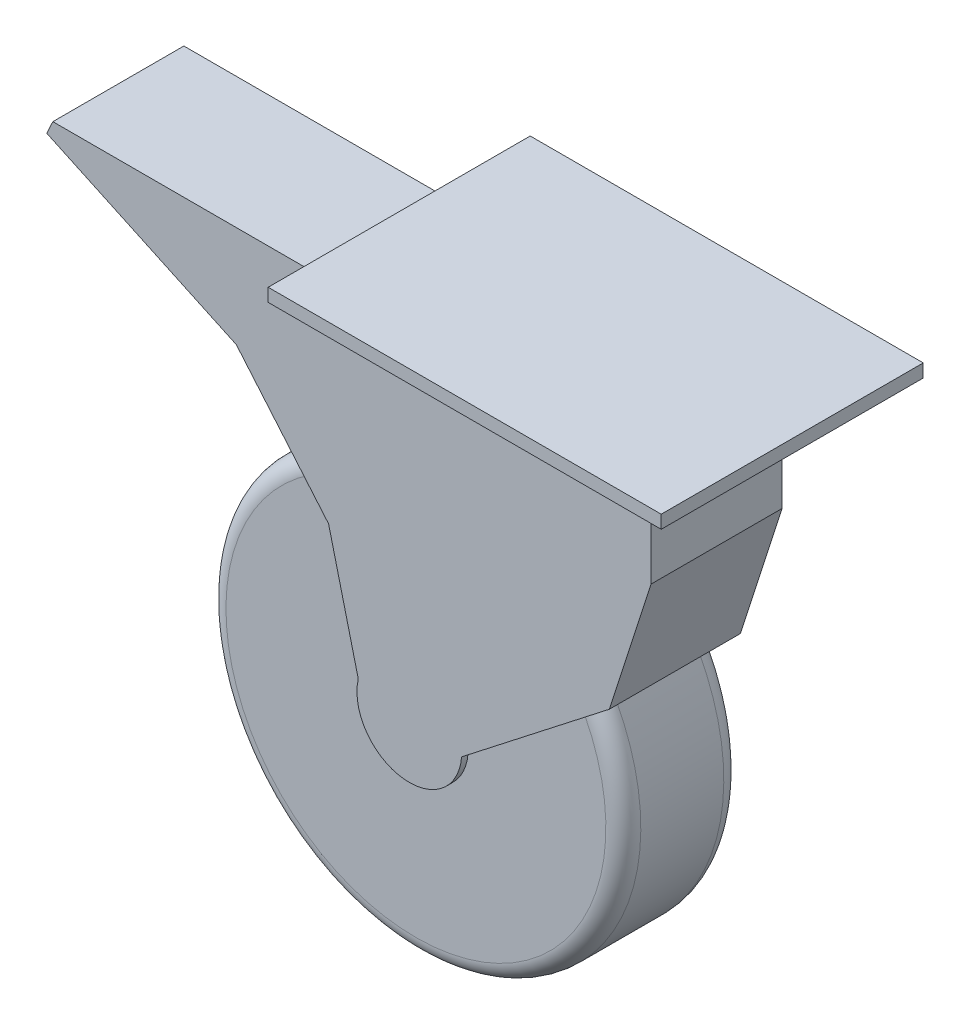
from build123d import *

# Parameters (mm, degrees)
SKETCH1_R                = 47.5
BOSS_EXTRUDE1_DEPTH      = 13.5
BOSS_EXTRUDE1_DEPTH_BACK = 13.5
FILLET1_R                = 4
BOSS_EXTRUDE2_DEPTH      = 15
BOSS_EXTRUDE2_DEPTH_BACK = 15
SKETCH5_W                = 90
SKETCH5_H                = 60
BOSS_EXTRUDE3_DEPTH      = 3


with BuildPart() as part:
    # Sketch1 → Boss-Extrude1 (new body, two sides)
    with BuildSketch(Plane.XY) as boss_extrude1_sk:
        Circle(SKETCH1_R)
    extrude(amount=BOSS_EXTRUDE1_DEPTH)
    extrude(boss_extrude1_sk.sketch, amount=-BOSS_EXTRUDE1_DEPTH_BACK)

    # Fillet1
    fillet1_edges = [part.edges().sort_by_distance(p)[0] for p in [
        (-47.5, 0, 13.5),
        (-47.5, 0, -13.5),
    ]]
    fillet(fillet1_edges, radius=FILLET1_R)

    # Sketch2 → Boss-Extrude2 (add, two sides)
    with BuildSketch(Plane.XY) as boss_extrude2_sk:
        with BuildLine():
            Line((-11.696785431, 2.681397647), (-18.496519497, 30.047194196))
            Line((-18.496519497, 30.047194196), (-39.614315725, 55.004751509))
            Line((-39.614315725, 55.004751509), (-83.032226589, 75.23))
            Line((-83.032226589, 75.23), (-81.634744669, 78.23))
            Line((-81.634744669, 78.23), (0, 78.23))
            Line((0, 78.23), (0, 82.04))
            Line((0, 82.04), (55.339662837, 82.04))
            Line((55.339662837, 82.04), (55.339662837, 55.004751509))
            Line((55.339662837, 55.004751509), (45.787278668, 25.414095095))
            Line((45.787278668, 25.414095095), (11.963303828, -0.940236292))
            ThreePointArc((11.963303828, -0.940236292), (-1.815713665, -11.862034676), (-11.696785431, 2.681397647))
        make_face()
    extrude(amount=BOSS_EXTRUDE2_DEPTH)
    extrude(boss_extrude2_sk.sketch, amount=-BOSS_EXTRUDE2_DEPTH_BACK)

    # Sketch5 → Boss-Extrude3 (add)
    with BuildSketch(Plane(origin=(0, 82.04, 0), x_dir=(1, 0, 0), z_dir=(0, 1, 0))):
        with Locations((27.669831419, 0)):
            Rectangle(SKETCH5_W, SKETCH5_H)
    extrude(amount=BOSS_EXTRUDE3_DEPTH)


solid = part.part
